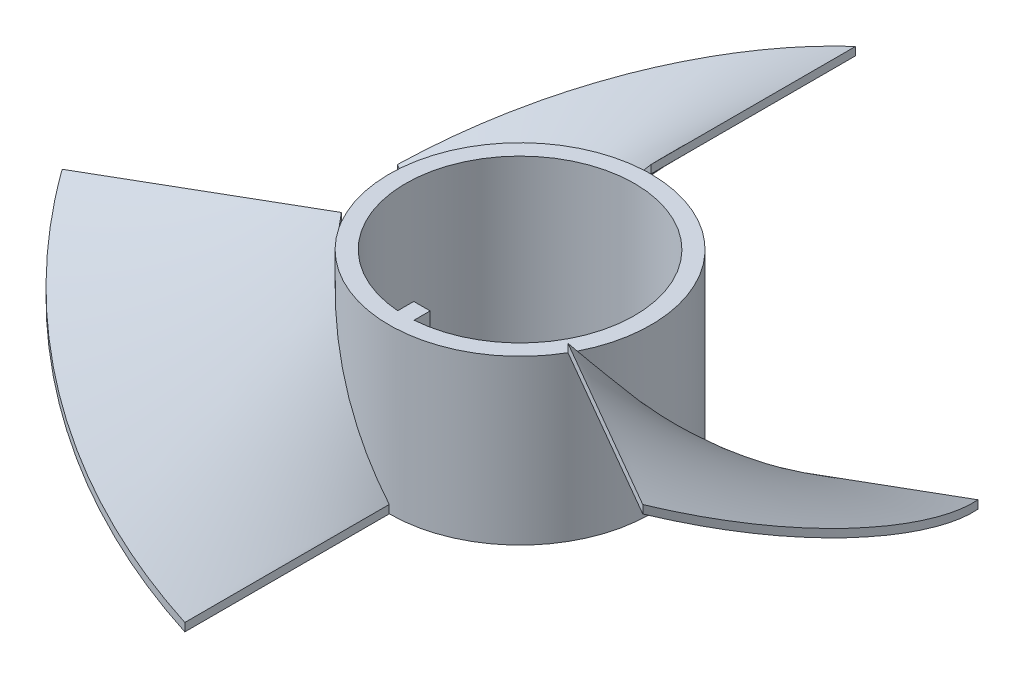
from build123d import *

# Parameters (mm, degrees)
SKETCH1_R           = 16
BOSS_EXTRUDE1_DEPTH = 20
SKETCH3_W           = 25
SKETCH3_H           = 1
CIRPATTERN1_COUNT   = 3


with BuildPart() as part:
    # Sketch1 → Boss-Extrude1 (new body)
    with BuildSketch(Plane(origin=(0, 0, 0), x_dir=(1, 0, 0), z_dir=(0, 1, 0))):
        with Locations(Location((0, 0, 0), (0, 0, 270))):
            Circle(SKETCH1_R)
        with BuildLine():
            Line((-1, -12), (1, -12))
            Line((1, -12), (1, -13.964240044))
            ThreePointArc((1, -13.964240044), (0, 14), (-1, -13.964240044))
            Line((-1, -13.964240044), (-1, -12))
        make_face(mode=Mode.SUBTRACT)
    extrude(amount=BOSS_EXTRUDE1_DEPTH)

    # Sweep1: sweep along a curve in space
    with BuildLine() as sweep1_path:
        add(Edge.make_bspline(
            [(0, 0, 16), (-1.857798397, 2.217583486, 16), (-5.586575728, 6.669449908, 15.343093774), (-10.494221117, 13.330550092, 12.509663387), (-12.927507262, 17.782416514, 9.608900607), (-13.856406461, 20, 8)],
            knots=[0, 0, 0, 0, 0.333333333, 0.666666667, 1, 1, 1, 1], degree=3))
    with BuildLine() as sweep1_axis:
        Line((0, 0, 0), (0, 20, 0))
    # Sketch3 → Sweep1 (sweep)
    with BuildSketch(Plane(origin=(0, 0, 0), x_dir=(0, 0, -1), z_dir=(1, 0, 0))):
        with Locations((-28.5, 0.5)):
            Rectangle(SKETCH3_W, SKETCH3_H)
    sweep1 = sweep(path=sweep1_path.line, binormal=sweep1_axis.edges()[0])

    # CirPattern1: Sweep1 ×3 about axis
    cirpattern1_axis = Axis((0, -1.105625, 0), (0, 1, 0))
    for i in range(1, CIRPATTERN1_COUNT):
        add(sweep1.rotate(cirpattern1_axis, i * 360 / CIRPATTERN1_COUNT))


solid = part.part
